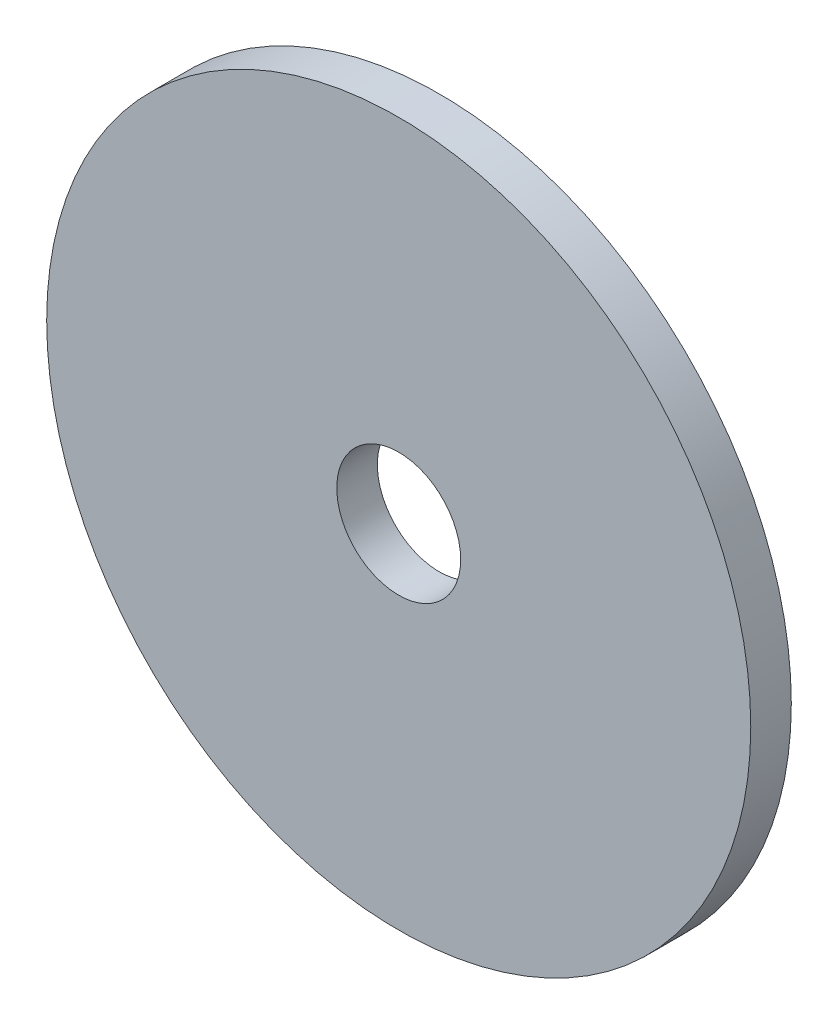
from build123d import *

# Parameters (mm, degrees)
SKETCH1_R           = 12.5
SKETCH1_R_2         = 2.2
BOSS_EXTRUDE1_DEPTH = 1.44


with BuildPart() as part:
    # Sketch1 → Boss-Extrude1 (new body)
    with BuildSketch(Plane.XY):
        Circle(SKETCH1_R)
        Circle(SKETCH1_R_2, mode=Mode.SUBTRACT)
    extrude(amount=BOSS_EXTRUDE1_DEPTH)


solid = part.part
